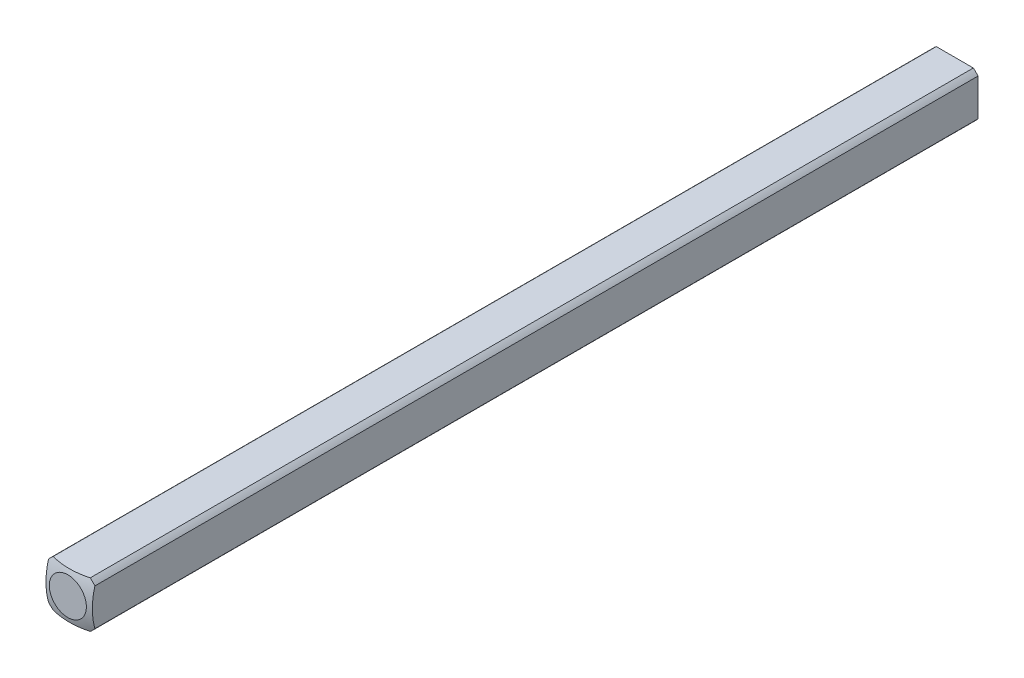
from build123d import *

# Parameters (mm, degrees)
SKETCH1_W           = 3.175
SKETCH1_H           = 3.175
BOSS_EXTRUDE1_DEPTH = 152.4
SKETCH2_OUTSIDE_W   = 35.668
SKETCH2_OUTSIDE_H   = 35.668
SKETCH2_OUTSIDE_R   = 2.032
CUT_EXTRUDE1_DEPTH  = 153.4
CUT_EXTRUDE2_DEPTH  = 4.175
SKETCH6_W           = 3.175
SKETCH6_H           = 12.7
CUT_EXTRUDE3_DEPTH  = 4.175
SKETCH7_W           = 3.175
SKETCH7_H           = 27.94
CUT_EXTRUDE4_DEPTH  = 4.175


with BuildPart() as part:
    # Sketch1 → Boss-Extrude1 (new body)
    with BuildSketch(Plane.XY):
        Rectangle(SKETCH1_W, SKETCH1_H)
    extrude(amount=BOSS_EXTRUDE1_DEPTH)

    # Sketch2 outside → Cut-Extrude1 (cut, through all)
    with BuildSketch(Plane(origin=(0, 0, 0), x_dir=(-1, 0, 0), z_dir=(0, 0, -1))):
        Rectangle(SKETCH2_OUTSIDE_W, SKETCH2_OUTSIDE_H)
        Circle(SKETCH2_OUTSIDE_R, mode=Mode.SUBTRACT)
    extrude(amount=-CUT_EXTRUDE1_DEPTH, mode=Mode.SUBTRACT)

    # Sketch3 → Cut-Revolve1 (revolve, cut)
    with BuildSketch(Plane(origin=(0, 0, 0), x_dir=(1, 0, 0), z_dir=(0, 1, 0))):
        with BuildLine():
            Line((-5.053685963, -4.40273269), (-5.053685963, 5.740530545))
            Line((-5.053685963, 5.740530545), (0, 5.740530545))
            Line((0, 5.740530545), (0, 0.160877736))
            ThreePointArc((0, 0.160877736), (-3.404639553, -1.148866368), (-5.053685963, -4.40273269))
        make_face()
    revolve(axis=Axis((0, 0, 152.4), (0, 0, -1)), mode=Mode.SUBTRACT)

    # Mirror1: part across plane


with BuildPart() as part_1:
    add(part.part)
    add(part.part.mirror(Plane(origin=(0, 0, 152.4), x_dir=(1, 0, 0), z_dir=(0, 0, -1))))

    # Sketch4 → Cut-Extrude2 (cut, through all)
    with BuildSketch(Plane(origin=(1.5875, 0, 0), x_dir=(0, 0, -1), z_dir=(1, 0, 0))):
        Polygon((-0.263225358, -1.5875), (-203.463225358, -1.5875), (-203.463225358, 1.5875), (-0.263225358, 1.5875), (0.835678169, 1.5875), (0.835678169, -1.5875), align=None)
    extrude(amount=-CUT_EXTRUDE2_DEPTH, mode=Mode.SUBTRACT)

    # Sketch6 → Cut-Extrude3 (cut, through all)
    with BuildSketch(Plane.XZ.offset(1.5875)):
        with Locations((0, 209.813225358)):
            Rectangle(SKETCH6_W, SKETCH6_H)
    extrude(amount=-CUT_EXTRUDE3_DEPTH, mode=Mode.SUBTRACT)

    # Sketch7 → Cut-Extrude4 (cut, through all)
    with BuildSketch(Plane.XZ.offset(1.5875)):
        with Locations((0, 230.133225358)):
            Rectangle(SKETCH7_W, SKETCH7_H)
    extrude(amount=-CUT_EXTRUDE4_DEPTH, mode=Mode.SUBTRACT)


solid = part_1.part
